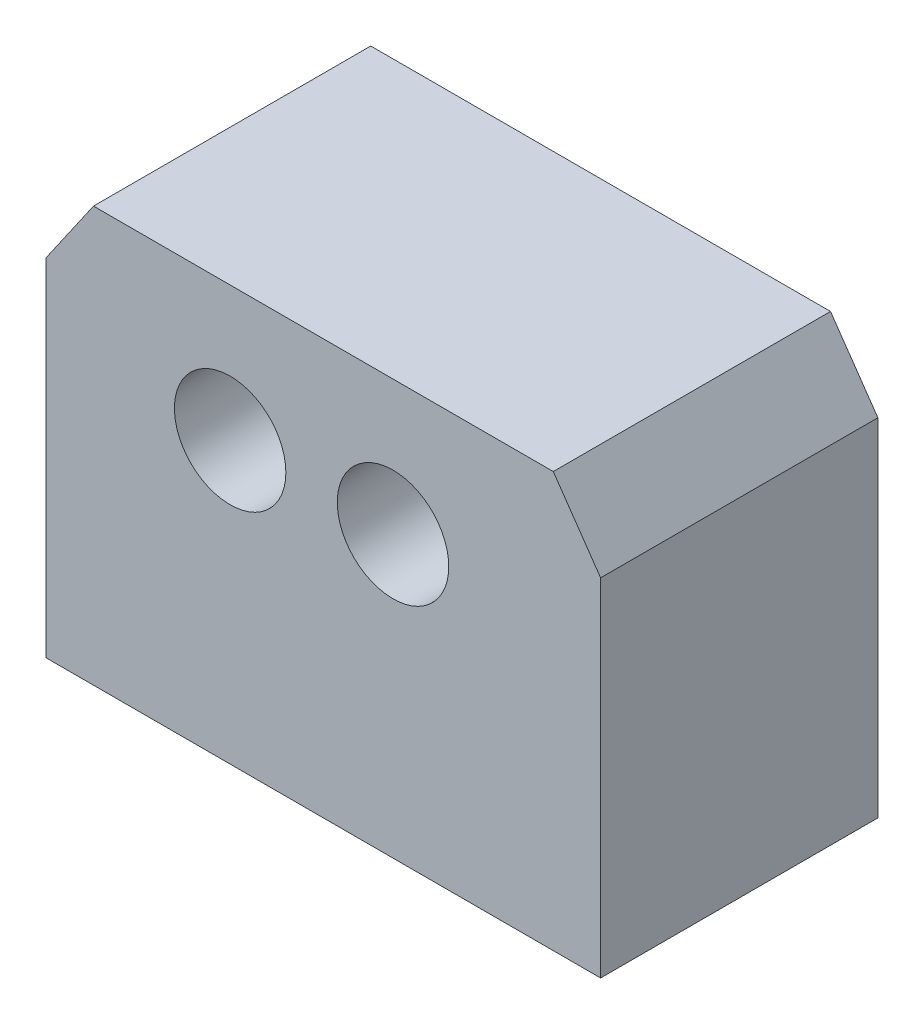
from build123d import *

# Parameters (mm, degrees)
ESBO_O1_R                = 4.020297227
RESSALTO_EXTRUS_O1_DEPTH = 20
ESBO_O2_W                = 40
ESBO_O2_H                = 20
RESSALTO_EXTRUS_O2_DEPTH = 10


with BuildPart() as part:
    # Esboço1 → Ressalto-extrusão1 (new body)
    with BuildSketch(Plane.XY):
        Polygon((19.906301529, -10.222394025), (-20.093698471, -10.222394025), (-20.093698471, 4.777605975), (-16.677218189, 9.709914003), (16.489821246, 9.709914003), (19.906301529, 4.777605975), align=None)
        with Locations((-6.819904998, 0)):
            Circle(ESBO_O1_R, mode=Mode.SUBTRACT)
        with Locations((4.930095002, 0)):
            Circle(ESBO_O1_R, mode=Mode.SUBTRACT)
    extrude(amount=RESSALTO_EXTRUS_O1_DEPTH)

    # Esboço2 → Ressalto-extrusão2 (add)
    with BuildSketch(Plane.XZ.offset(10.222394025)):
        with Locations((-0.093698471, 10)):
            Rectangle(ESBO_O2_W, ESBO_O2_H)
    extrude(amount=RESSALTO_EXTRUS_O2_DEPTH)


solid = part.part
